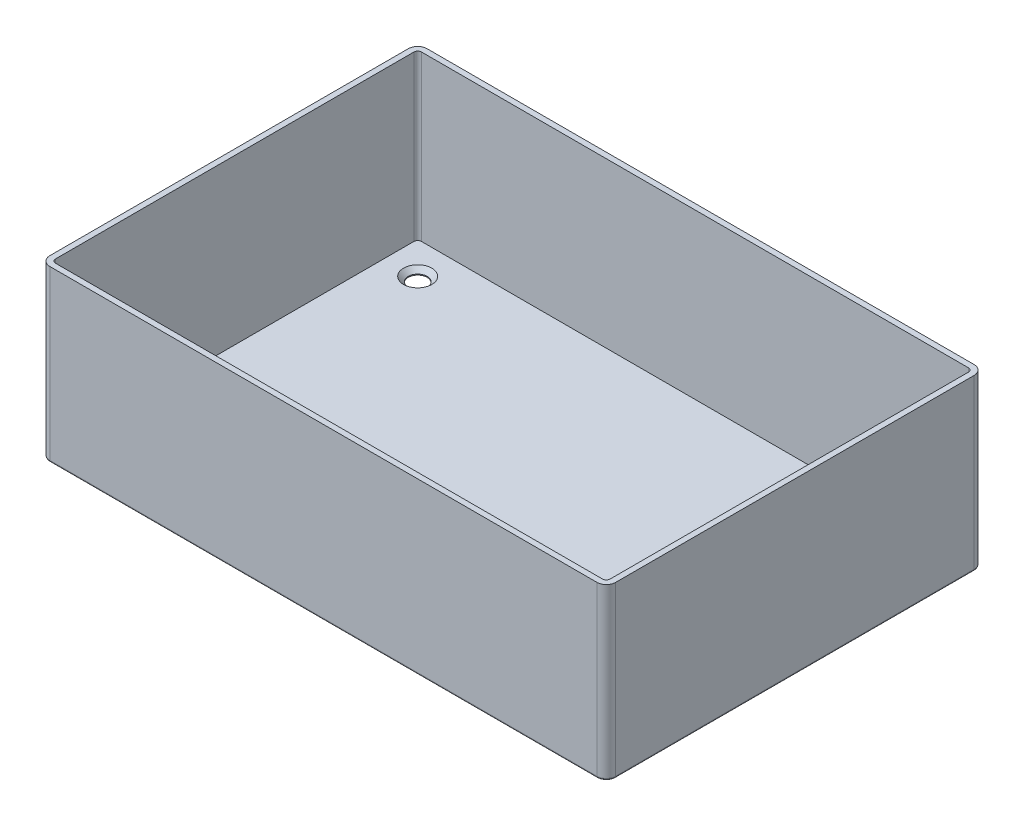
from build123d import *

# Parameters (mm, degrees)
BOSS_EXTRUDE1_DEPTH = 50
SHELL1_T            = -1.5
SKETCH2_R           = 2.5
CUT_EXTRUDE1_DEPTH  = 50
SKETCH3_OUTSIDE_W   = 189.504
SKETCH3_OUTSIDE_H   = 139.504
CUT_EXTRUDE2_DEPTH  = 5
CUT_EXTRUDE2_TAPER  = 0.5
FILLET1_R           = 0.5
CHAMFER1_SIZE       = 1.25


with BuildPart() as part:
    # Sketch1 → Boss-Extrude1 (new body)
    with BuildSketch(Plane(origin=(0, 0, 0), x_dir=(1, 0, 0), z_dir=(0, 1, 0))):
        with BuildLine():
            Line((-72.5, -50), (72.5, -50))
            ThreePointArc((72.5, -50), (74.267766953, -49.267766953), (75, -47.5))
            Line((75, -47.5), (75, 47.5))
            ThreePointArc((75, 47.5), (74.267766953, 49.267766953), (72.5, 50))
            Line((72.5, 50), (-72.5, 50))
            ThreePointArc((-72.5, 50), (-74.267766953, 49.267766953), (-75, 47.5))
            Line((-75, 47.5), (-75, -47.5))
            ThreePointArc((-75, -47.5), (-74.267766953, -49.267766953), (-72.5, -50))
        make_face()
    extrude(amount=BOSS_EXTRUDE1_DEPTH)

    # Shell1
    shell1_openings = [part.faces().sort_by_distance(p)[0] for p in [
        (0, 50, 0),
    ]]
    offset(amount=SHELL1_T, openings=shell1_openings, kind=Kind.INTERSECTION)

    # Sketch2 → Cut-Extrude1 (cut)
    with BuildSketch(Plane(origin=(0, 1.5, 0), x_dir=(1, 0, 0), z_dir=(0, 1, 0))):
        with Locations((-65, 40)):
            Circle(SKETCH2_R)
        with Locations((65, 40)):
            Circle(SKETCH2_R)
        with Locations((65, -40)):
            Circle(SKETCH2_R)
        with Locations((-65, -40)):
            Circle(SKETCH2_R)
    extrude(amount=-CUT_EXTRUDE1_DEPTH, mode=Mode.SUBTRACT)

    # Sketch3 outside → Cut-Extrude2 (cut)
    with BuildSketch(Plane(origin=(0, 50, 0), x_dir=(1, 0, 0), z_dir=(0, 1, 0))):
        Rectangle(SKETCH3_OUTSIDE_W, SKETCH3_OUTSIDE_H)
        with BuildLine():
            Line((-69.232233047, -45.732233047), (69.232233047, -45.732233047))
            ThreePointArc((69.232233047, -45.732233047), (70.292893219, -45.292893219), (70.732233047, -44.232233047))
            Line((70.732233047, -44.232233047), (70.732233047, 44.232233047))
            ThreePointArc((70.732233047, 44.232233047), (70.292893219, 45.292893219), (69.232233047, 45.732233047))
            Line((69.232233047, 45.732233047), (-69.232233047, 45.732233047))
            ThreePointArc((-69.232233047, 45.732233047), (-70.292893219, 45.292893219), (-70.732233047, 44.232233047))
            Line((-70.732233047, 44.232233047), (-70.732233047, -44.232233047))
            ThreePointArc((-70.732233047, -44.232233047), (-70.292893219, -45.292893219), (-69.232233047, -45.732233047))
        make_face(mode=Mode.SUBTRACT)
    extrude(amount=-CUT_EXTRUDE2_DEPTH, taper=CUT_EXTRUDE2_TAPER, mode=Mode.SUBTRACT)

    # Fillet1
    fillet1_edges = [part.edges().sort_by_distance(p)[0] for p in [
        (-75, 0, 0),
        (-74.267766953, 0, -49.267766953),
        (0, 0, -50),
        (74.267766953, 0, -49.267766953),
        (75, 0, 0),
        (74.267766953, 0, 49.267766953),
        (0, 0, 50),
        (-74.267766953, 0, 49.267766953),
    ]]
    fillet(fillet1_edges, radius=FILLET1_R)

    # Chamfer1
    chamfer1_edges = [part.edges().sort_by_distance(p)[0] for p in [
        (-67.5, 1.5, -40),
        (62.5, 1.5, -40),
        (62.5, 1.5, 40),
        (-67.5, 1.5, 40),
    ]]
    chamfer(chamfer1_edges, length=CHAMFER1_SIZE)


solid = part.part
